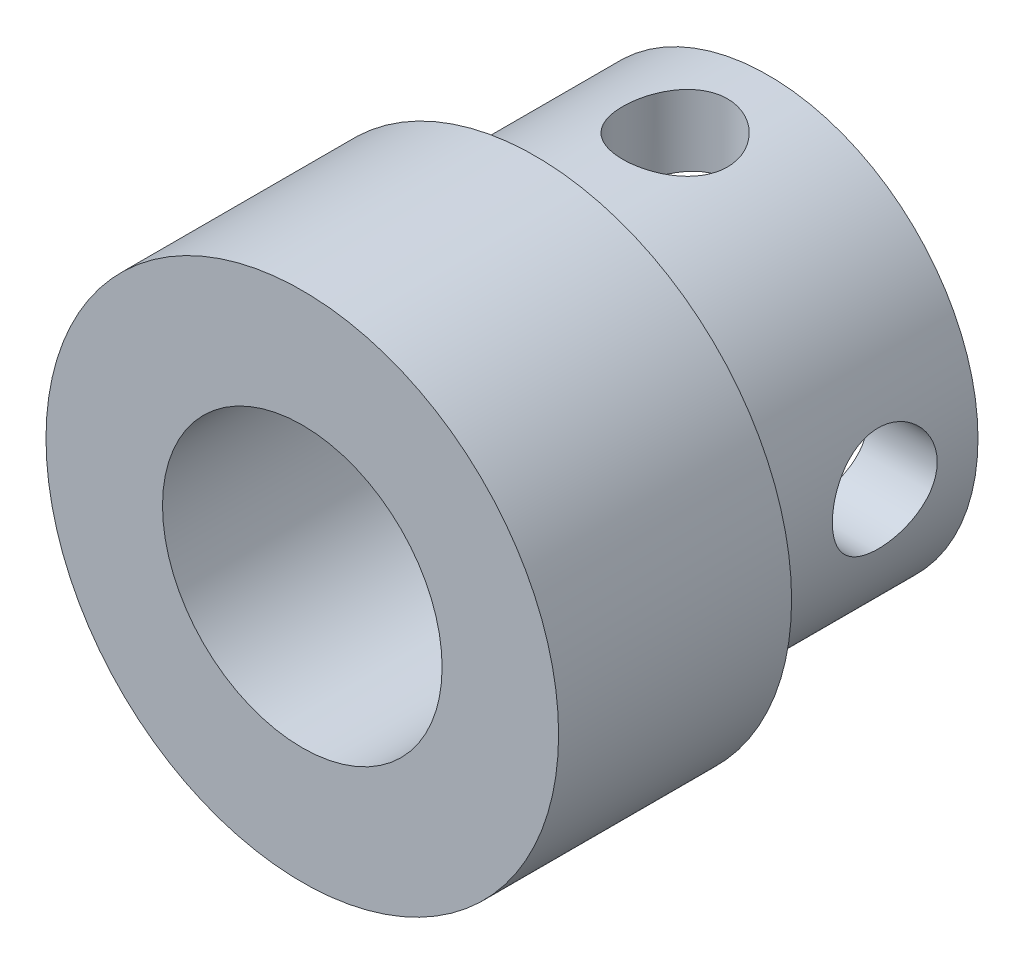
from build123d import *

# Parameters (mm, degrees)
ESQUISSE1_R                = 11
ESQUISSE1_R_2              = 6
BOSS_EXTRU_1_DEPTH         = 10
ESQUISSE2_R                = 9
ESQUISSE2_R_2              = 6
BOSS_EXTRU_2_DEPTH         = 10
D_GAGEMENT_M41_D           = 4.5
D_GAGEMENT_M41_ON_FACE_2_D = 4.5


with BuildPart() as part:
    # Esquisse1 → Boss.-Extru.1 (new body)
    with BuildSketch(Plane.XY):
        Circle(ESQUISSE1_R)
        Circle(ESQUISSE1_R_2, mode=Mode.SUBTRACT)
    extrude(amount=BOSS_EXTRU_1_DEPTH)

    # Esquisse2 → Boss.-Extru.2 (add)
    with BuildSketch(Plane(origin=(0, 0, 0), x_dir=(-1, 0, 0), z_dir=(0, 0, -1))):
        Circle(ESQUISSE2_R)
        Circle(ESQUISSE2_R_2, mode=Mode.SUBTRACT)
    extrude(amount=BOSS_EXTRU_2_DEPTH)

    # Dégagement M41 (through all)
    with Locations(Plane(origin=(0, 9, -6), x_dir=(1, 0, 0), z_dir=(0, 1, 0))):
        with Locations((0, 0)):
            Hole(D_GAGEMENT_M41_D / 2)

    # Dégagement M41 on face 2 (through all)
    with Locations(Plane(origin=(-9, 0, -6), x_dir=(0, 0, -1), z_dir=(-1, 0, 0))):
        with Locations((0, 0)):
            Hole(D_GAGEMENT_M41_ON_FACE_2_D / 2)


solid = part.part
